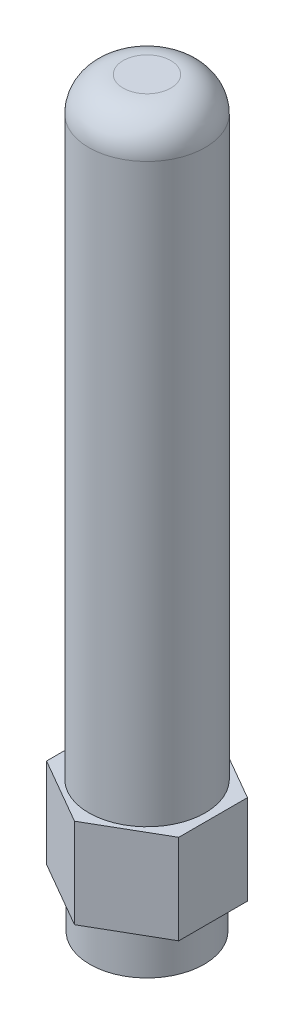
from build123d import *

# Parameters (mm, degrees)
SKETCH1_R           = 3.81
SKETCH1_R_2         = 2.667
BOSS_EXTRUDE1_DEPTH = 2.794
BOSS_EXTRUDE2_DEPTH = 5.969
SKETCH4_R           = 3.8735
BOSS_EXTRUDE3_DEPTH = 40.64
FILLET1_R           = 2.286


with BuildPart() as part:
    # Sketch1 → Boss-Extrude1 (new body)
    with BuildSketch(Plane(origin=(0, 0, 0), x_dir=(1, 0, 0), z_dir=(0, 1, 0))):
        Circle(SKETCH1_R)
        Circle(SKETCH1_R_2, mode=Mode.SUBTRACT)
    extrude(amount=BOSS_EXTRUDE1_DEPTH)

    # Sketch3 → Boss-Extrude2 (add)
    with BuildSketch(Plane(origin=(0, 2.794, 0), x_dir=(1, 0, 0), z_dir=(0, 1, 0))):
        Polygon((-4.399409051, -2.286), (-4.399409051, 2.286), (0, 4.826), (4.399409051, 2.286), (4.399409051, -2.286), (0, -4.826), align=None)
    extrude(amount=BOSS_EXTRUDE2_DEPTH)

    # Sketch4 → Boss-Extrude3 (add)
    with BuildSketch(Plane(origin=(0, 8.763, 0), x_dir=(1, 0, 0), z_dir=(0, 1, 0))):
        Circle(SKETCH4_R)
    extrude(amount=BOSS_EXTRUDE3_DEPTH)

    # Fillet1
    fillet1_edges = [part.edges().sort_by_distance(p)[0] for p in [
        (-3.8735, 49.403, 0),
    ]]
    fillet(fillet1_edges, radius=FILLET1_R)


solid = part.part
